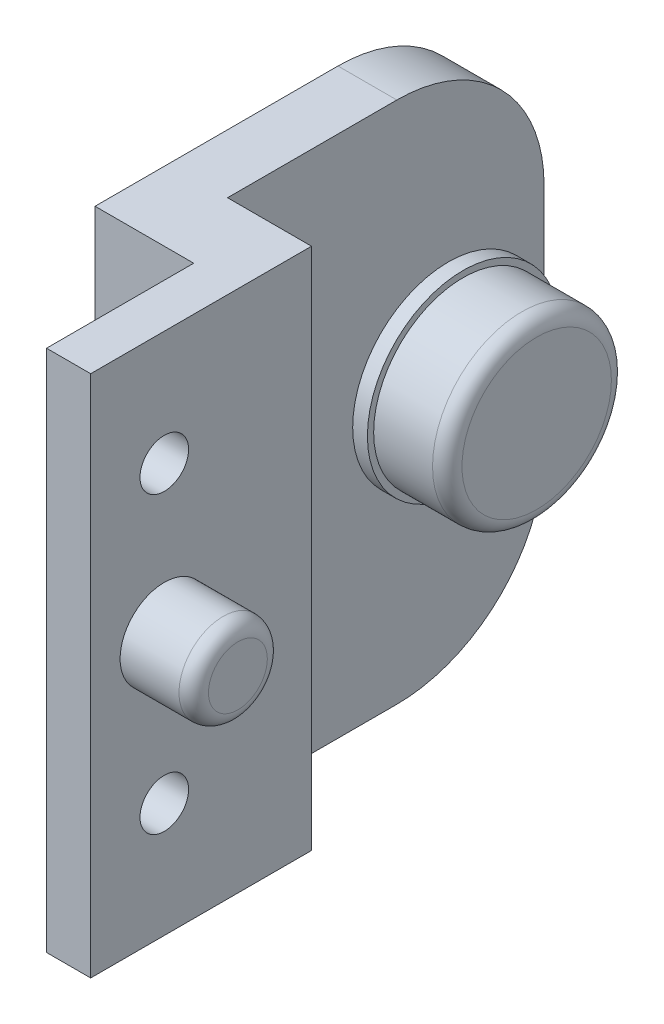
from build123d import *

# Parameters (mm, degrees)
SKETCH4_W                = 12.46
SKETCH4_H                = 17.25
BOSS_EXTRUDE3_DEPTH      = 6
SKETCH8_R                = 12.546781182
SKETCH8_R_2              = 11.15
BOSS_EXTRUDE6_DEPTH      = 8.3
BOSS_EXTRUDE6_DEPTH_BACK = 17.25
BOSS_EXTRUDE4_DEPTH      = 17.25
SKETCH6_R                = 0.75
CUT_EXTRUDE1_DEPTH       = 5
CHAMFER1_SIZE            = 0.5
CHAMFER1_SIZE2           = 0.866025404
SKETCH10_W               = 12.46
SKETCH10_H               = 23.7
CUT_EXTRUDE3_DEPTH       = 17.25
BOSS_EXTRUDE7_DEPTH      = 8.3
BOSS_EXTRUDE9_DEPTH      = 10
SKETCH20_R               = 11.15
SKETCH20_R_2             = 7.15
BOSS_EXTRUDE11_DEPTH     = 8.3
SKETCH21_R               = 10.15
SKETCH21_R_2             = 7.15
CUT_EXTRUDE7_DEPTH       = 1.3
SKETCH11_W               = 10
SKETCH11_H               = 2
CUT_EXTRUDE4_DEPTH       = 23.7
CUT_EXTRUDE8_REACH       = 37.55
SKETCH25_W               = 12.46
SKETCH25_H               = 6
BOSS_EXTRUDE10_DEPTH     = 35.55
SKETCH18_W               = 21.5
SKETCH18_H               = 11.438292938
CUT_EXTRUDE5_DEPTH       = 2
SKETCH19_R               = 3.5
CUT_EXTRUDE6_DEPTH       = 43.5
CUT_EXTRUDE6_DEPTH_BACK  = 3
FILLET1_R                = 10
SKETCH22_R               = 6.5
BOSS_EXTRUDE12_DEPTH     = 5
SKETCH23_R               = 6.075
BOSS_EXTRUDE13_DEPTH     = 5
FILLET2_R                = 1
BOSS_EXTRUDE14_DEPTH     = 2
CUT_EXTRUDE9_REACH       = 46.5
SKETCH27_R               = 0.75
CUT_EXTRUDE10_DEPTH      = 36.55
SKETCH29_W               = 3
SKETCH29_H               = 35.55
BOSS_EXTRUDE15_DEPTH     = 10
SKETCH30_R               = 3
BOSS_EXTRUDE16_DEPTH     = 5
FILLET3_R                = 1
SKETCH31_R               = 1.65
CUT_EXTRUDE11_DEPTH      = 23.25


with BuildPart() as part:
    # Sketch4 → Boss-Extrude3 (new body)
    with BuildSketch(Plane.XY):
        with Locations((0, -1.35)):
            Rectangle(SKETCH4_W, SKETCH4_H)
    extrude(amount=BOSS_EXTRUDE3_DEPTH)



with BuildPart() as body_2:
    # Sketch8 → Boss-Extrude6 (new body, two sides)
    with BuildSketch(Plane(origin=(0, -9.975, 0), x_dir=(-1, 0, 0), z_dir=(0, -1, 0))) as boss_extrude6_sk:
        with Locations((0, -23.55)):
            Circle(SKETCH8_R)
        with Locations((0, -23.55)):
            Circle(SKETCH8_R_2, mode=Mode.SUBTRACT)
    extrude(amount=BOSS_EXTRUDE6_DEPTH)
    extrude(boss_extrude6_sk.sketch, amount=-BOSS_EXTRUDE6_DEPTH_BACK)


with BuildPart() as part_1:
    add(part.part)

    add(body_2.part)  # Boss-Extrude4 merges body 2
    # Sketch5 → Boss-Extrude4 (add)
    with BuildSketch(Plane(origin=(0, 7.275, 0), x_dir=(1, 0, 0), z_dir=(0, 1, 0))):
        with BuildLine():
            Line((12.546781182, -23.55), (12.546781182, 0))
            Line((12.546781182, 0), (6.23, 0))
            Line((6.23, 0), (6.23, -29.7))
            Line((6.23, -29.7), (-6.23, -29.7))
            Line((-6.23, -29.7), (-6.23, 0))
            Line((-6.23, 0), (-12.546781182, 0))
            Line((-12.546781182, 0), (-12.546781182, -23.55))
            ThreePointArc((-12.546781182, -23.55), (0, -36.096781182), (12.546781182, -23.55))
        make_face()
    extrude(amount=-BOSS_EXTRUDE4_DEPTH)

    # Sketch6 → Cut-Extrude1 (cut)
    with BuildSketch(Plane(origin=(0, 7.275, 0), x_dir=(1, 0, 0), z_dir=(0, 1, 0))):
        with Locations((0, -3.6)):
            Circle(SKETCH6_R)
        with Locations((0, -32.1)):
            Circle(SKETCH6_R)
    extrude(amount=-CUT_EXTRUDE1_DEPTH, mode=Mode.SUBTRACT)

    # Chamfer1
    chamfer1_edges = [part_1.edges().sort_by_distance(p)[0] for p in [
        (-0.75, 7.275, 3.6),
        (-0.75, 7.275, 32.1),
    ]]
    chamfer1_side = [part_1.faces().sort_by_distance(p)[0] for p in [
        (0, 7.275, 35.657160381),
    ]]
    chamfer(chamfer1_edges, length=CHAMFER1_SIZE, length2=CHAMFER1_SIZE2, reference=chamfer1_side[0])

    # Sketch10 → Cut-Extrude3 (cut)
    with BuildSketch(Plane(origin=(0, 7.275, 0), x_dir=(1, 0, 0), z_dir=(0, 1, 0))):
        with Locations((0, -17.85)):
            Rectangle(SKETCH10_W, SKETCH10_H)
    extrude(amount=-CUT_EXTRUDE3_DEPTH, mode=Mode.SUBTRACT)

    # Sketch13 → Boss-Extrude7 (add)
    with BuildSketch(Plane.XZ.offset(18.275)):
        with BuildLine():
            Line((-12.546781182, 23.55), (-12.546781182, 0))
            Line((-12.546781182, 0), (12.546781182, 0))
            Line((12.546781182, 0), (12.546781182, 23.55))
            ThreePointArc((12.546781182, 23.55), (0, 11.003218818), (-12.546781182, 23.55))
        make_face()
    extrude(amount=-BOSS_EXTRUDE7_DEPTH)

    # Sketch15 → Boss-Extrude9 (add)
    with BuildSketch(Plane(origin=(0, 7.275, 0), x_dir=(1, 0, 0), z_dir=(0, 1, 0))):
        with BuildLine():
            Line((-12.546781182, 0), (12.546781182, 0))
            Line((12.546781182, 0), (12.546781182, -23.55))
            ThreePointArc((12.546781182, -23.55), (0, -36.096781182), (-12.546781182, -23.55))
            Line((-12.546781182, -23.55), (-12.546781182, 0))
        make_face()
        with BuildLine():
            Line((-6.23, -0.8), (6.23, -0.8))
            Line((6.23, -0.8), (6.23, -33))
            ThreePointArc((6.23, -33), (5.790660172, -34.060660172), (4.73, -34.5))
            Line((4.73, -34.5), (-4.73, -34.5))
            ThreePointArc((-4.73, -34.5), (-5.790660172, -34.060660172), (-6.23, -33))
            Line((-6.23, -33), (-6.23, -0.8))
        make_face(mode=Mode.SUBTRACT)
    extrude(amount=BOSS_EXTRUDE9_DEPTH)

    # Sketch20 → Boss-Extrude11 (add)
    with BuildSketch(Plane.XZ.offset(18.275)):
        with Locations((0, 23.55)):
            Circle(SKETCH20_R)
        with Locations((0, 23.55)):
            Circle(SKETCH20_R_2, mode=Mode.SUBTRACT)
    extrude(amount=-BOSS_EXTRUDE11_DEPTH)

    # Sketch21 → Cut-Extrude7 (cut)
    with BuildSketch(Plane.XZ.offset(18.275)):
        with Locations((0, 23.55)):
            Circle(SKETCH21_R)
        with Locations((0, 23.55)):
            Circle(SKETCH21_R_2, mode=Mode.SUBTRACT)
    extrude(amount=-CUT_EXTRUDE7_DEPTH, mode=Mode.SUBTRACT)

    # Sketch11 → Cut-Extrude4 (cut)
    with BuildSketch(Plane.XY.offset(29.7)):
        with Locations((0, -10.975)):
            Rectangle(SKETCH11_W, SKETCH11_H)
    extrude(amount=-CUT_EXTRUDE4_DEPTH, mode=Mode.SUBTRACT)

    # Sketch25 → Cut-Extrude8 (cut, up to next)
    with BuildSketch(Plane.XZ.offset(18.275), mode=Mode.PRIVATE) as cut_extrude8_sk1:
        with Locations((0, 9)):
            Rectangle(SKETCH25_W, SKETCH25_H)
    cut_extrude8_tool1 = extrude(cut_extrude8_sk1.sketch, amount=-CUT_EXTRUDE8_REACH, mode=Mode.PRIVATE) & part_1.part
    add(cut_extrude8_tool1.solids().sort_by_distance((0, -18.275, 9))[0], mode=Mode.SUBTRACT)

    # Sketch17 → Boss-Extrude10 (add)
    with BuildSketch(Plane(origin=(0, 17.275, 0), x_dir=(1, 0, 0), z_dir=(0, 1, 0))):
        Polygon((22.25, 26.5), (22.25, 0), (-22.25, 0), (-22.25, 26.5), (-18.25, 26.5), (-18.25, 5), (18.25, 5), (18.25, 26.5), align=None)
    extrude(amount=-BOSS_EXTRUDE10_DEPTH)

    # Sketch18 → Cut-Extrude5 (cut)
    with BuildSketch(Plane.ZY.offset(-18.25)):
        with Locations((-15.75, -0.5)):
            Rectangle(SKETCH18_W, SKETCH18_H)
    extrude(amount=-CUT_EXTRUDE5_DEPTH, mode=Mode.SUBTRACT)

    # Sketch19 → Cut-Extrude6 (cut, two sides)
    with BuildSketch(Plane.ZY.offset(-20.25)) as cut_extrude6_sk:
        with Locations((-20, -0.5)):
            Circle(SKETCH19_R)
    extrude(amount=CUT_EXTRUDE6_DEPTH, mode=Mode.SUBTRACT)
    extrude(cut_extrude6_sk.sketch, amount=-CUT_EXTRUDE6_DEPTH_BACK, mode=Mode.SUBTRACT)

    # Fillet1
    fillet1_edges = [part_1.edges().sort_by_distance(p)[0] for p in [
        (20.25, 17.275, -26.5),
        (-20.25, 17.275, -26.5),
        (-20.25, -18.275, -26.5),
        (20.25, -18.275, -26.5),
    ]]
    fillet(fillet1_edges, radius=FILLET1_R)

    # Sketch22 → Boss-Extrude12 (add)
    with BuildSketch(Plane.ZY.offset(22.25)):
        with Locations((-20, -0.5)):
            Circle(SKETCH22_R)
    extrude(amount=-BOSS_EXTRUDE12_DEPTH)

    # Sketch23 → Boss-Extrude13 (add)
    with BuildSketch(Plane(origin=(-17.25, 0, 0), x_dir=(0, 0, -1), z_dir=(1, 0, 0))):
        with Locations((20, -0.5)):
            Circle(SKETCH23_R)
    extrude(amount=BOSS_EXTRUDE13_DEPTH)

    # Fillet2
    fillet2_edges = [part_1.edges().sort_by_distance(p)[0] for p in [
        (-12.25, -0.5, -13.925),
    ]]
    fillet(fillet2_edges, radius=FILLET2_R)

    # Sketch26 → Boss-Extrude14 (add)
    with BuildSketch(Plane.ZY.offset(-20.25)):
        Polygon((-5, 2), (-20, 2.6585), (-26.5, 2.94385), (-26.5, 5.219146469), (-5, 5.219146469), align=None)
        Polygon((-20, -3.6585), (-5, -3), (-5, -6.219146469), (-26.5, -6.219146469), (-26.5, -3.94385), align=None)
    extrude(amount=BOSS_EXTRUDE14_DEPTH)

    # Sketch27 → Cut-Extrude9 (cut, up to next)
    with BuildSketch(Plane(origin=(22.25, 0, 0), x_dir=(0, 0, -1), z_dir=(1, 0, 0)), mode=Mode.PRIVATE) as cut_extrude9_sk1:
        with Locations((10, -0.5)):
            Circle(SKETCH27_R)
    cut_extrude9_tool1 = extrude(cut_extrude9_sk1.sketch, amount=-CUT_EXTRUDE9_REACH, mode=Mode.PRIVATE) & part_1.part
    add(cut_extrude9_tool1.solids().sort_by_distance((22.25, -0.5, -10))[0], mode=Mode.SUBTRACT)

    # Sketch28 → Cut-Extrude10 (cut, through all)
    with BuildSketch(Plane(origin=(0, 17.275, 0), x_dir=(1, 0, 0), z_dir=(0, 1, 0))):
        Polygon((-12.546781182, 11.805014222), (-12.546781182, -42.756283402), (39.689088419, -42.756283402), (38.70358058, 30.977621269), (-8.600795685, 28.379464239), align=None)
    extrude(amount=-CUT_EXTRUDE10_DEPTH, mode=Mode.SUBTRACT)

    # Sketch29 → Boss-Extrude15 (add)
    with BuildSketch(Plane.XY):
        with Locations((-14.046781182, -0.5)):
            Rectangle(SKETCH29_W, SKETCH29_H)
    extrude(amount=BOSS_EXTRUDE15_DEPTH)

    # Sketch30 → Boss-Extrude16 (add)
    with BuildSketch(Plane(origin=(-12.546781182, 0, 0), x_dir=(0, 0, -1), z_dir=(1, 0, 0))):
        with Locations((-5, -0.5)):
            Circle(SKETCH30_R)
    extrude(amount=BOSS_EXTRUDE16_DEPTH)

    # Fillet3
    fillet3_edges = [part_1.edges().sort_by_distance(p)[0] for p in [
        (-7.546781182, -0.5, 8),
    ]]
    fillet(fillet3_edges, radius=FILLET3_R)

    # Sketch31 → Cut-Extrude11 (cut, through all)
    with BuildSketch(Plane(origin=(0, 0, 0), x_dir=(0, 0, -1), z_dir=(1, 0, 0))):
        with Locations((-5, 9.5)):
            Circle(SKETCH31_R)
        with Locations((-5, -10.5)):
            Circle(SKETCH31_R)
    extrude(amount=-CUT_EXTRUDE11_DEPTH, mode=Mode.SUBTRACT)


solid = part_1.part
